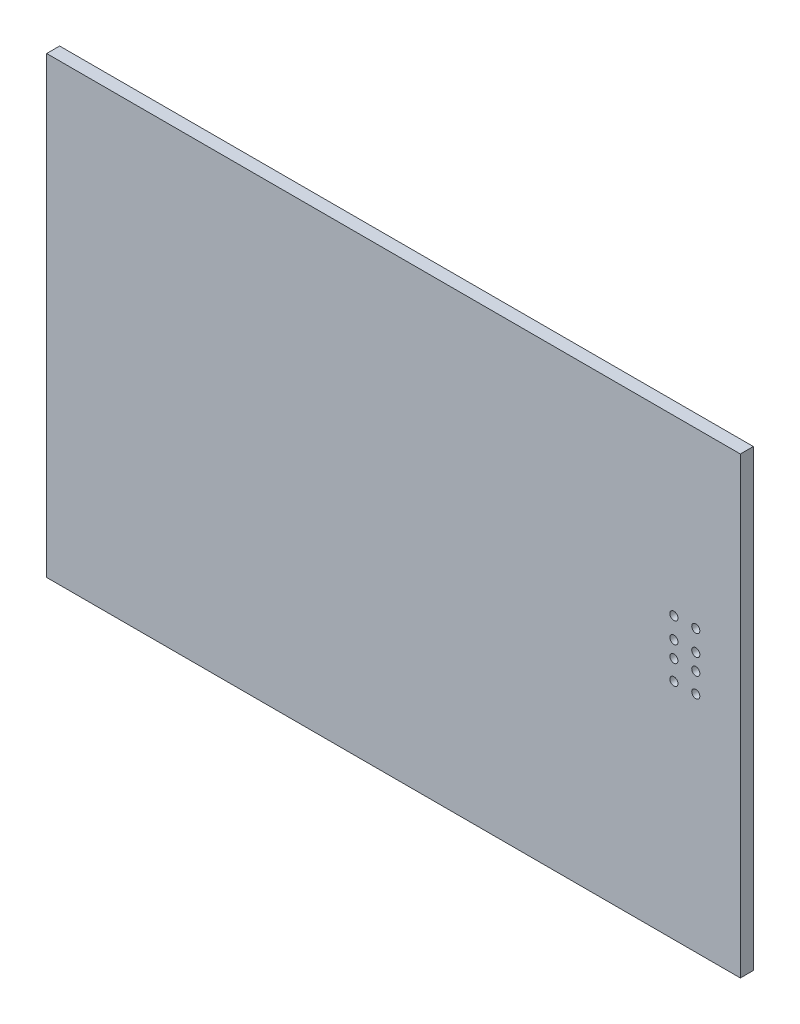
from build123d import *

# Parameters (mm, degrees)
ESBO_O1_W                = 85.6
ESBO_O1_H                = 56
RESSALTO_EXTRUS_O1_DEPTH = 1.6
ESBO_O2_R                = 0.5
CORTE_EXTRUS_O1_DEPTH    = 2


with BuildPart() as part:
    # Esboço1 → Ressalto-extrusão1 (new body)
    with BuildSketch(Plane(origin=(0, 0, 0), x_dir=(-1, 0, 0), z_dir=(0, 0, -1))):
        with Locations((0.3, 0)):
            Rectangle(ESBO_O1_W, ESBO_O1_H)
    extrude(amount=-RESSALTO_EXTRUS_O1_DEPTH)

    # Esboço2 → Corte-extrusão1 (cut)
    with BuildSketch(Plane.XY.offset(1.6)):
        with Locations((37, 6.6)):
            Circle(ESBO_O2_R)
        with Locations((34.3, 6.6)):
            Circle(ESBO_O2_R)
        with Locations((34.3, 4.05)):
            Circle(ESBO_O2_R)
        with Locations((34.3, 2.04)):
            Circle(ESBO_O2_R)
        with Locations((34.3, -0.4)):
            Circle(ESBO_O2_R)
        with Locations((37, 4.05)):
            Circle(ESBO_O2_R)
        with Locations((37, 2.04)):
            Circle(ESBO_O2_R)
        with Locations((37, -0.4)):
            Circle(ESBO_O2_R)
    extrude(amount=-CORTE_EXTRUS_O1_DEPTH, mode=Mode.SUBTRACT)


solid = part.part
